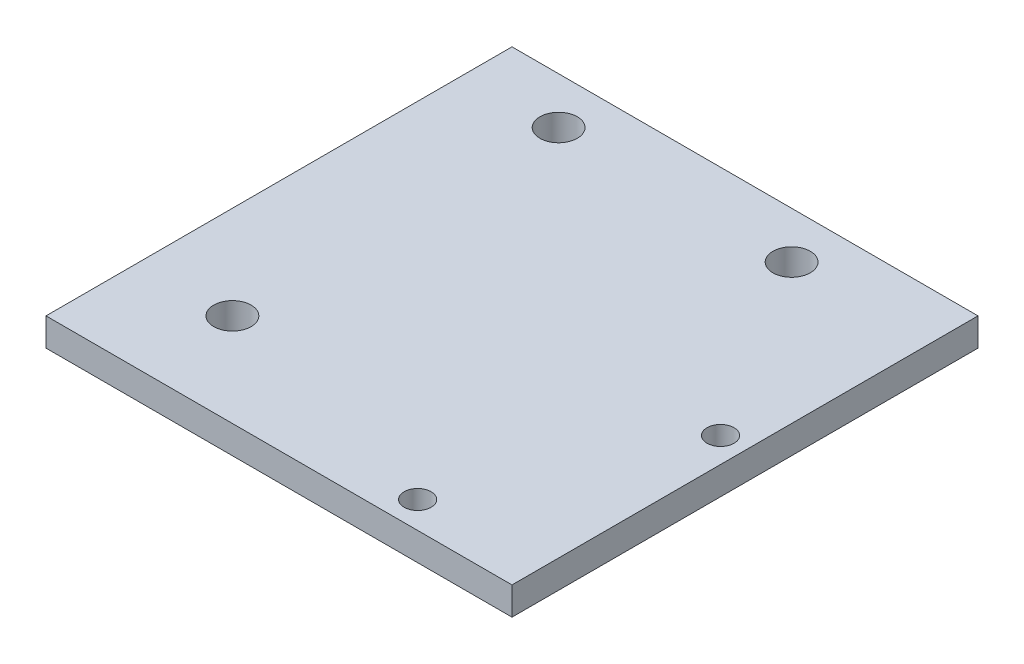
from build123d import *

# Parameters (mm, degrees)
SKETCH1_W           = 50
SKETCH1_H           = 50
BOSS_EXTRUDE1_DEPTH = 3
SKETCH2_R           = 2.0066
CUT_EXTRUDE1_DEPTH  = 4
CUT_EXTRUDE2_REACH  = 5
SKETCH3_R           = 1.45


with BuildPart() as part:
    # Sketch1 → Boss-Extrude1 (new body)
    with BuildSketch(Plane(origin=(0, 0, 0), x_dir=(1, 0, 0), z_dir=(0, 1, 0))):
        with Locations((25, 25)):
            Rectangle(SKETCH1_W, SKETCH1_H)
    extrude(amount=BOSS_EXTRUDE1_DEPTH)

    # Sketch2 → Cut-Extrude1 (cut, through all)
    with BuildSketch(Plane(origin=(0, 3, 0), x_dir=(1, 0, 0), z_dir=(0, 1, 0))):
        with Locations((10, 45)):
            Circle(SKETCH2_R)
        with Locations((35, 45)):
            Circle(SKETCH2_R)
        with Locations((10, 10)):
            Circle(SKETCH2_R)
    extrude(amount=-CUT_EXTRUDE1_DEPTH, mode=Mode.SUBTRACT)

    # Sketch3 → Cut-Extrude2 (cut, up to next)
    with BuildSketch(Plane(origin=(0, 3, 0), x_dir=(1, 0, 0), z_dir=(0, 1, 0)), mode=Mode.PRIVATE) as cut_extrude2_sk1:
        with Locations((47.301711452, 25.073921106)):
            Circle(SKETCH3_R)
    cut_extrude2_tool1 = extrude(cut_extrude2_sk1.sketch, amount=-CUT_EXTRUDE2_REACH, mode=Mode.PRIVATE) & part.part
    add(cut_extrude2_tool1.solids().sort_by_distance((47.301711, 3, -25.073921))[0], mode=Mode.SUBTRACT)
    # Sketch3 → Cut-Extrude2 (cut, up to next)
    with BuildSketch(Plane(origin=(0, 3, 0), x_dir=(1, 0, 0), z_dir=(0, 1, 0)), mode=Mode.PRIVATE) as cut_extrude2_sk2:
        with Locations((37.001711452, 2.873921106)):
            Circle(SKETCH3_R)
    cut_extrude2_tool2 = extrude(cut_extrude2_sk2.sketch, amount=-CUT_EXTRUDE2_REACH, mode=Mode.PRIVATE) & part.part
    add(cut_extrude2_tool2.solids().sort_by_distance((37.001711, 3, -2.873921))[0], mode=Mode.SUBTRACT)


solid = part.part
